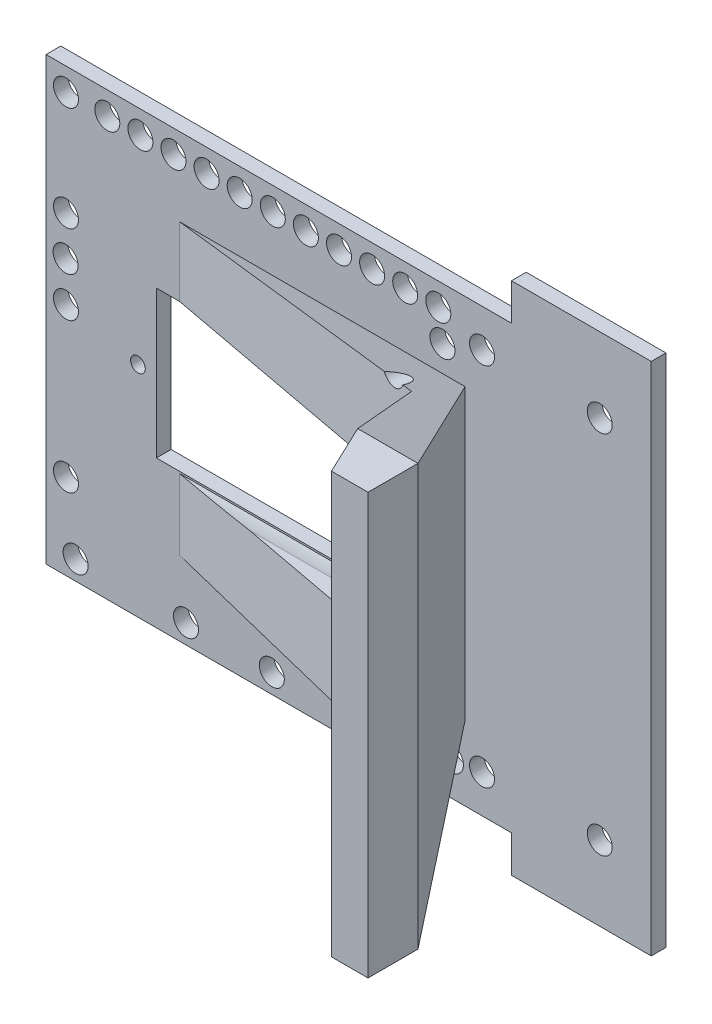
from build123d import *

# Parameters (mm, degrees)
ESQUISSE1_W             = 19
ESQUISSE1_H             = 70
ESQUISSE1_R             = 1.7
BOSS_EXTRU_1_DEPTH      = 2
ESQUISSE2_W             = 65
ESQUISSE2_H             = 60
BOSS_EXTRU_2_DEPTH      = 2
ESQUISSE3_R             = 1.7
ESQUISSE3_R_2           = 1
ENL_V_MAT_EXTRU_1_DEPTH = 2
ESQUISSE4_R             = 1.7
ENL_V_MAT_EXTRU_2_DEPTH = 2
ESQUISSE5_W             = 31.414941094
ESQUISSE5_H             = 20
ENL_V_MAT_EXTRU_3_DEPTH = 10
BOSS_EXTRU_7_DEPTH      = 28
ENL_V_MAT_EXTRU_4_DEPTH = 60
ENL_V_MAT_EXTRU_5_DEPTH = 72
ENL_V_MAT_EXTRU_6_DEPTH = 67
ENL_V_MAT_EXTRU_7_DEPTH = 35
BOSS_EXTRU_11_DEPTH     = 2
ESQUISSE15_R            = 1.7
ENL_V_MAT_EXTRU_8_DEPTH = 10


with BuildPart() as part:
    # Esquisse1 → Boss.-Extru.1 (new body)
    with BuildSketch(Plane.XY):
        with Locations((-2.5, -24.85)):
            Rectangle(ESQUISSE1_W, ESQUISSE1_H)
        Circle(ESQUISSE1_R, mode=Mode.SUBTRACT)
        with Locations((0, -49.7)):
            Circle(ESQUISSE1_R, mode=Mode.SUBTRACT)
    extrude(amount=BOSS_EXTRU_1_DEPTH)

    # Esquisse2 → Boss.-Extru.2 (add)
    with BuildSketch(Plane(origin=(0, 0, 0), x_dir=(-1, 0, 0), z_dir=(0, 0, -1))):
        with Locations((42.768488136, -24.85)):
            Rectangle(ESQUISSE2_W, ESQUISSE2_H)
    extrude(amount=-BOSS_EXTRU_2_DEPTH)

    # Esquisse3 → Enlèv. mat.-Extru.1 (cut)
    with BuildSketch(Plane(origin=(0, 0, 0), x_dir=(-1, 0, 0), z_dir=(0, 0, -1))):
        with Locations((56.248017163, -52.23632124)):
            Circle(ESQUISSE3_R)
        with Locations((25.480085092, -25.094879292)):
            Circle(ESQUISSE3_R_2)
        with Locations((62.780085092, -25.094879292)):
            Circle(ESQUISSE3_R_2)
        with Locations((71.248017163, -52.23632124)):
            Circle(ESQUISSE3_R)
        with Locations((21.945704193, 2.053157955)):
            Circle(ESQUISSE3_R)
        with Locations((26.445704193, 2.053157955)):
            Circle(ESQUISSE3_R)
        with Locations((30.945704193, 2.053157955)):
            Circle(ESQUISSE3_R)
        with Locations((35.445704193, 2.053157955)):
            Circle(ESQUISSE3_R)
        with Locations((72.562852247, -43.246842045)):
            Circle(ESQUISSE3_R)
        with Locations((72.562852247, -22.946842045)):
            Circle(ESQUISSE3_R)
        with Locations((72.562852247, -12.146842045)):
            Circle(ESQUISSE3_R)
        with Locations((72.562852247, 2.053157955)):
            Circle(ESQUISSE3_R)
        with Locations((25.480085092, -52.23632124)):
            Circle(ESQUISSE3_R)
        with Locations((44.580085092, -52.23632124)):
            Circle(ESQUISSE3_R)
        with Locations((39.945704193, 2.053157955)):
            Circle(ESQUISSE3_R)
        with Locations((44.445704193, 2.053157955)):
            Circle(ESQUISSE3_R)
        with Locations((48.945704193, 2.053157955)):
            Circle(ESQUISSE3_R)
        with Locations((53.445704193, 2.053157955)):
            Circle(ESQUISSE3_R)
        with Locations((57.945704193, 2.053157955)):
            Circle(ESQUISSE3_R)
        with Locations((62.445704193, 2.053157955)):
            Circle(ESQUISSE3_R)
        with Locations((66.945704193, 2.053157955)):
            Circle(ESQUISSE3_R)
    extrude(amount=-ENL_V_MAT_EXTRU_1_DEPTH, mode=Mode.SUBTRACT)

    # Esquisse4 → Enlèv. mat.-Extru.2 (cut)
    with BuildSketch(Plane(origin=(0, 0, 0), x_dir=(-1, 0, 0), z_dir=(0, 0, -1))):
        with Locations((16, -49.7)):
            Circle(ESQUISSE4_R)
        with Locations((16, 0)):
            Circle(ESQUISSE4_R)
    extrude(amount=-ENL_V_MAT_EXTRU_2_DEPTH, mode=Mode.SUBTRACT)

    # Esquisse5 → Enlèv. mat.-Extru.3 (cut)
    with BuildSketch(Plane(origin=(0, 0, 0), x_dir=(-1, 0, 0), z_dir=(0, 0, -1))):
        with Locations((44.561017589, -24.85)):
            Rectangle(ESQUISSE5_W, ESQUISSE5_H)
    extrude(amount=-ENL_V_MAT_EXTRU_3_DEPTH, mode=Mode.SUBTRACT)

    # Esquisse9 → Boss.-Extru.7 (add)
    with BuildSketch(Plane.XY.offset(2)):
        Polygon((-3.5, -53.689758583), (-3.5, 3.5), (-28.853547042, 3.5), (-60.346670852, 3.5), (-60.346670852, -53.689758583), (-28.853547042, -53.689758583), align=None)
    extrude(amount=BOSS_EXTRU_7_DEPTH)

    # Esquisse10 → Enlèv. mat.-Extru.4 (cut)
    with BuildSketch(Plane(origin=(0, 3.5, 0), x_dir=(1, 0, 0), z_dir=(0, 1, 0))):
        Polygon((-18.30138002, -2), (-3.5, -2), (-3.5, -23.208493493), align=None)
        Polygon((-8.472856096, -30), (-18.30138002, -9.274207286), (-57.123898362, -2), (-60.855534618, -2), (-60.855534618, -30), (-28.853547042, -30), align=None)
    extrude(amount=-ENL_V_MAT_EXTRU_4_DEPTH, mode=Mode.SUBTRACT)

    # Esquisse11 → Enlèv. mat.-Extru.5 (cut)
    with BuildSketch(Plane(origin=(7, 0, 0), x_dir=(0, 0, -1), z_dir=(1, 0, 0))):
        Polygon((-23.208493493, 3.5), (-2, -5.465834256), (-2, 3.5), align=None)
        Polygon((-2, -44.723924327), (-2, -53.689758583), (-23.208493493, -53.689758583), align=None)
    extrude(amount=-ENL_V_MAT_EXTRU_5_DEPTH, mode=Mode.SUBTRACT)

    # Esquisse12 → Enlèv. mat.-Extru.6 (cut)
    with BuildSketch(Plane(origin=(7, 0, 0), x_dir=(0, 0, -1), z_dir=(1, 0, 0))):
        with BuildLine():
            Line((-2, -15.094879292), (-2, -35.094879292))
            ThreePointArc((-2, -35.094879292), (-6.168544771, -34.184611658), (-9.578191265, -31.619526191))
            Line((-9.578191265, -31.619526191), (-19.578951758, -25.094879292))
            Line((-19.578951758, -25.094879292), (-9.578191265, -18.570232393))
            ThreePointArc((-9.578191265, -18.570232393), (-6.168544771, -16.005146925), (-2, -15.094879292))
        make_face()
    extrude(amount=-ENL_V_MAT_EXTRU_6_DEPTH, mode=Mode.SUBTRACT)

    # Esquisse13 → Enlèv. mat.-Extru.7 (cut)
    with BuildSketch(Plane.XY.offset(2)):
        with BuildLine():
            Line((-60.268488136, -14.85), (-22.770000782, -14.85))
            Line((-22.770000782, -14.85), (-22.770000782, -20.893041237))
            ThreePointArc((-22.770000782, -20.893041237), (-20.480085092, -25.094879292), (-22.770000782, -29.296717346))
            Line((-22.770000782, -29.296717346), (-22.770000782, -34.85))
            Line((-22.770000782, -34.85), (-60.268488136, -34.85))
            Line((-60.268488136, -34.85), (-60.268488136, -14.85))
        make_face()
    extrude(amount=ENL_V_MAT_EXTRU_7_DEPTH, mode=Mode.SUBTRACT)

    # Esquisse14 → Boss.-Extru.11 (add)
    with BuildSketch(Plane(origin=(-13.245694898, 0, 9.244153239), x_dir=(-0.572305295, 0, -0.820040639), z_dir=(0.820040639, 0, -0.572305295))):
        Polygon((8.833895415, -35.094879292), (10.168090758, -35.094879292), (10.168090758, -15.094879292), (8.833895415, -15.094879292), (-13.439734278, -15.094879292), (-13.439734278, -35.094879292), align=None)
    extrude(amount=-BOSS_EXTRU_11_DEPTH)

    # Esquisse15 → Enlèv. mat.-Extru.8 (cut)
    with BuildSketch(Plane(origin=(0, 0, 0), x_dir=(-1, 0, 0), z_dir=(0, 0, -1))):
        with Locations((20.233733499, -50.143649221)):
            Circle(ESQUISSE15_R)
        with Locations((21.376751472, -1.943649221)):
            Circle(ESQUISSE15_R)
        with Locations((72.616751472, -17.553649221)):
            Circle(ESQUISSE15_R)
    extrude(amount=-ENL_V_MAT_EXTRU_8_DEPTH, mode=Mode.SUBTRACT)


solid = part.part
